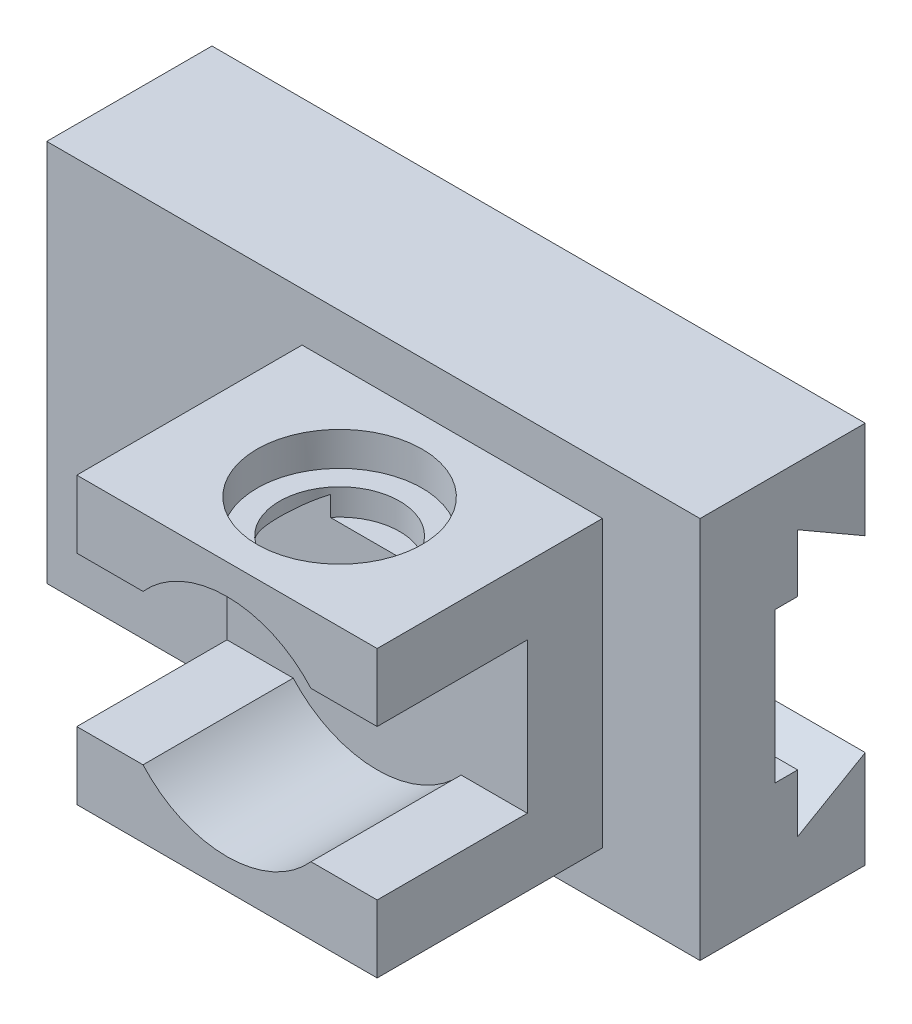
from build123d import *

# Parameters (mm, degrees)
SKETCH1_W         = 87
SKETCH1_H         = 50.982
BASE_YELLOW_DEPTH = 22
SKETCH5_W         = 40
SKETCH5_H         = 38
BASE_RED_DEPTH    = 30
BASE_TURKIZ_DEPTH = 88
SKETCH2_R         = 11
COUNTERBOR_DEPTH  = 4.5
SKETCH7_R         = 15
SKETCH7_W         = 40
SKETCH7_H         = 20
BASE_PURPLE_DEPTH = 20
SKETCH2_5_R       = 8
COUNTERBOR2_DEPTH = 8


with BuildPart() as part:
    # Sketch1 → base-yellow (new body)
    with BuildSketch(Plane.XY):
        Rectangle(SKETCH1_W, SKETCH1_H)
    extrude(amount=-BASE_YELLOW_DEPTH)

    # Sketch5 → base-red (add)
    with BuildSketch(Plane.XY):
        with Locations((10.5, 0)):
            Rectangle(SKETCH5_W, SKETCH5_H)
    extrude(amount=BASE_RED_DEPTH)

    # Sketch8 → base-turkiz (cut, through all)
    with BuildSketch(Plane.ZY.offset(43.5)):
        Polygon((-10, 10), (-10, -10), (-13, -10), (-13, -17.696152423), (-22, -12.5), (-22, 12.5), (-13, 17.696152423), (-13, 10), align=None)
    extrude(amount=-BASE_TURKIZ_DEPTH, mode=Mode.SUBTRACT)

    # Sketch2 → counterbor (cut)
    with BuildSketch(Plane(origin=(0, 19, -19), x_dir=(1, 0, 0), z_dir=(0, -1, 0))):
        with Locations((10.5, 34)):
            Circle(SKETCH2_R)
    extrude(amount=COUNTERBOR_DEPTH, mode=Mode.SUBTRACT)

    # Sketch7 → base-purple (cut)
    with BuildSketch(Plane.XY.offset(30)):
        with Locations((10.5, 0)):
            Circle(SKETCH7_R)
        with Locations((10.5, 0)):
            Rectangle(SKETCH7_W, SKETCH7_H)
    extrude(amount=-BASE_PURPLE_DEPTH, mode=Mode.SUBTRACT)

    # Sketch2_5 → counterbor2 (cut)
    with BuildSketch(Plane(origin=(0, 19, -19), x_dir=(1, 0, 0), z_dir=(0, -1, 0))):
        with Locations((10.5, 34)):
            Circle(SKETCH2_5_R)
    extrude(amount=COUNTERBOR2_DEPTH, mode=Mode.SUBTRACT)


solid = part.part
